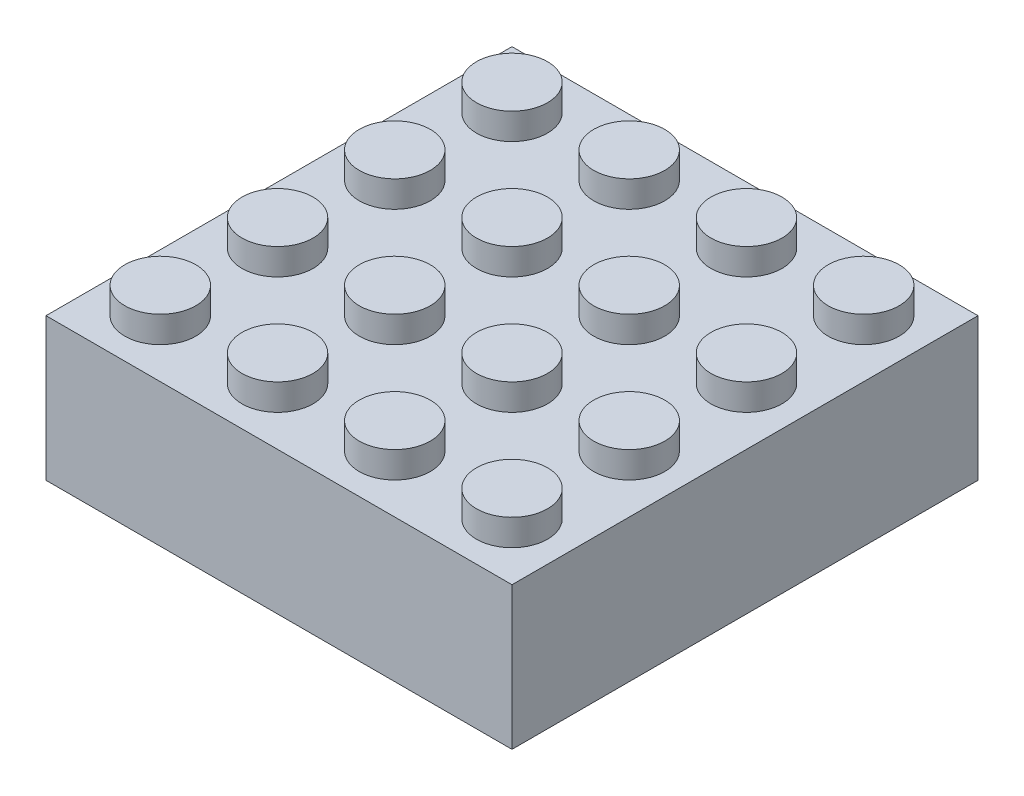
from build123d import *

# Parameters (mm, degrees)
SKETCH2_R              = 2.425
BOSS_EXTRUDE1_DEPTH    = 1.8
BOSS_EXTRUDE1_2_DEPTH  = 1.8
BOSS_EXTRUDE1_3_DEPTH  = 1.8
BOSS_EXTRUDE1_4_DEPTH  = 1.8
BOSS_EXTRUDE1_5_DEPTH  = 1.8
BOSS_EXTRUDE1_6_DEPTH  = 1.8
BOSS_EXTRUDE1_7_DEPTH  = 1.8
BOSS_EXTRUDE1_8_DEPTH  = 1.8
BOSS_EXTRUDE1_9_DEPTH  = 1.8
BOSS_EXTRUDE1_10_DEPTH = 1.8
BOSS_EXTRUDE1_11_DEPTH = 1.8
BOSS_EXTRUDE1_12_DEPTH = 1.8
BOSS_EXTRUDE1_13_DEPTH = 1.8
BOSS_EXTRUDE1_14_DEPTH = 1.8
BOSS_EXTRUDE1_15_DEPTH = 1.8
BOSS_EXTRUDE1_16_DEPTH = 1.8
SKETCH1_W              = 31.8
SKETCH1_H              = 31.8
BOSS_EXTRUDE2_DEPTH    = 9.73
CUT_EXTRUDE1_DEPTH     = 6.63
SKETCH9_W              = 8.211044263
SKETCH9_H              = 1.75
BOSS_EXTRUDE4_DEPTH    = 1.5
BOSS_EXTRUDE5_DEPTH    = 8.211044
CUT_EXTRUDE4_DEPTH     = 8.211044
CIRPATTERN3_COUNT      = 6
BOSS_EXTRUDE6_DEPTH    = 0.3
CIRPATTERN4_COUNT      = 6
BOSS_EXTRUDE7_DEPTH    = 2
CIRPATTERN5_COUNT      = 6
MIRROR2_COPY_1_DEPTH   = 2
MIRROR2_COPY_2_DEPTH   = 2
MIRROR2_COPY_3_DEPTH   = 2
MIRROR2_COPY_4_DEPTH   = 2
MIRROR2_COPY_5_DEPTH   = 2
MIRROR2_COPY_6_DEPTH   = 2


with BuildPart() as part:
    # Sketch2 → Boss-Extrude1 (new body)
    with BuildSketch(Plane(origin=(0, 0, 0), x_dir=(1, 0, 0), z_dir=(0, 1, 0))):
        with Locations((3.9, 27.9)):
            Circle(SKETCH2_R)
    extrude(amount=BOSS_EXTRUDE1_DEPTH)

    # Sketch1 → Boss-Extrude2 (add)
    with BuildSketch(Plane(origin=(0, 0, 0), x_dir=(1, 0, 0), z_dir=(0, 1, 0))):
        with Locations((15.9, 15.9)):
            Rectangle(SKETCH1_W, SKETCH1_H)
    extrude(amount=-BOSS_EXTRUDE2_DEPTH)

    # Sketch4 → Cut-Extrude1 (cut)
    with BuildSketch(Plane.XZ.offset(9.73)):
        Polygon((26.085733965, -15.874437919), (21.016403127, -7.092489065), (10.805424678, -7.07984512), (5.714275589, -15.929121347), (10.830590574, -24.734643054), (21.015442313, -24.708069014), align=None)
    extrude(amount=-CUT_EXTRUDE1_DEPTH, mode=Mode.SUBTRACT)

    # Sketch9 → Boss-Extrude4 (add)
    with BuildSketch(Plane.XZ.offset(9.73)):
        with Locations((15.910946043, -6.206083389)):
            Rectangle(SKETCH9_W, SKETCH9_H)
    boss_extrude4 = extrude(amount=BOSS_EXTRUDE4_DEPTH)

    # Sketch10 → Boss-Extrude5 (add)
    with BuildSketch(Plane(origin=(20.016468174, 0, 0), x_dir=(0, 0, -1), z_dir=(1, 0, 0))):
        Polygon((7.081083389, -11.23), (7.981083389, -9.83), (7.081083389, -9.73), align=None)
    boss_extrude5 = extrude(amount=-BOSS_EXTRUDE5_DEPTH)

    # Sketch11 → Cut-Extrude4 (cut)
    with BuildSketch(Plane(origin=(20.016468174, 0, 0), x_dir=(0, 0, -1), z_dir=(1, 0, 0))):
        Polygon((6.331083389, -11.23), (5.331083389, -9.73), (5.331083389, -11.23), align=None)
    cut_extrude4 = extrude(amount=-CUT_EXTRUDE4_DEPTH, mode=Mode.SUBTRACT)

    # CirPattern3: Boss-Extrude4, Boss-Extrude5, Cut-Extrude4 ×6 about axis
    cirpattern3_axis = Axis((15.9, 0, -15.9), (0, 1, 0))
    for i in range(1, CIRPATTERN3_COUNT):
        add(boss_extrude4.rotate(cirpattern3_axis, i * 360 / CIRPATTERN3_COUNT))
        add(boss_extrude5.rotate(cirpattern3_axis, i * 360 / CIRPATTERN3_COUNT))
        add(cut_extrude4.rotate(cirpattern3_axis, i * 360 / CIRPATTERN3_COUNT), mode=Mode.SUBTRACT)

    # Sketch14 → Boss-Extrude6 (add, symmetric)
    with BuildSketch(Plane(origin=(10.895248778, 0, -18.812913342), x_dir=(0.86535523, 0, 0.501158983), z_dir=(-0.501158983, 0, 0.86535523))):
        Polygon((14.624999456, -3.1), (14.624999456, -8.639676715), (14.024999456, -3.1), align=None)
    boss_extrude6 = extrude(amount=BOSS_EXTRUDE6_DEPTH, both=True)

    # CirPattern4: Boss-Extrude6 ×6 about axis
    cirpattern4_axis = Axis((15.9, 0, -15.9), (0, 1, 0))
    for i in range(1, CIRPATTERN4_COUNT):
        add(boss_extrude6.rotate(cirpattern4_axis, i * 360 / CIRPATTERN4_COUNT))

    # Sketch18 → Boss-Extrude7 (add)
    with BuildSketch(Plane.ZY.offset(-11.805423911)):
        Polygon((-7.081083389, -11.23), (-7.081083389, -9.73), (-5.331083389, -9.73), (-6.331083389, -11.23), align=None)
    boss_extrude7 = extrude(amount=BOSS_EXTRUDE7_DEPTH)

    # CirPattern5: Boss-Extrude7 ×6 about axis
    cirpattern5_axis = Axis((15.9, 0, -15.9), (0, 1, 0))
    for i in range(1, CIRPATTERN5_COUNT):
        add(boss_extrude7.rotate(cirpattern5_axis, i * 360 / CIRPATTERN5_COUNT))

    # Mirror1: Boss-Extrude7 across plane
    add(boss_extrude7.mirror(Plane(origin=(15.919664079, 0, -0.019712838), x_dir=(0.001238269, 0, 0.999999233), z_dir=(0.999999233, 0, -0.001238269))))

    # Mirror2 copy 1 sketch → Mirror2 copy 1 (add)
    with BuildSketch(Plane(origin=(4.205990344, 0, -4.374997115), x_dir=(-0.86478448, 0, 0.50214321), z_dir=(0.50214321, 0, 0.86478448))):
        Polygon((-7.081083389, 11.23), (-7.081083389, 9.73), (-5.331083389, 9.73), (-6.331083389, 11.23), align=None)
    extrude(amount=MIRROR2_COPY_1_DEPTH)

    # Mirror2 copy 2 sketch → Mirror2 copy 2 (add)
    with BuildSketch(Plane(origin=(0.072049895, 0, -20.264807991), x_dir=(-0.867261016, 0, -0.497853724), z_dir=(-0.497853724, 0, 0.867261016))):
        Polygon((-7.081083389, 11.23), (-7.081083389, 9.73), (-5.331083389, 9.73), (-6.331083389, 11.23), align=None)
    extrude(amount=MIRROR2_COPY_2_DEPTH)

    # Mirror2 copy 3 sketch → Mirror2 copy 3 (add)
    with BuildSketch(Plane(origin=(11.766059551, 0, -31.789810877), x_dir=(-0.002476536, 0, -0.999996933), z_dir=(-0.999996933, 0, 0.002476536))):
        Polygon((-7.081083389, 11.23), (-7.081083389, 9.73), (-5.331083389, 9.73), (-6.331083389, 11.23), align=None)
    extrude(amount=MIRROR2_COPY_3_DEPTH)

    # Mirror2 copy 4 sketch → Mirror2 copy 4 (add)
    with BuildSketch(Plane(origin=(27.594009656, 0, -27.425002885), x_dir=(0.86478448, 0, -0.50214321), z_dir=(-0.50214321, 0, -0.86478448))):
        Polygon((-7.081083389, 11.23), (-7.081083389, 9.73), (-5.331083389, 9.73), (-6.331083389, 11.23), align=None)
    extrude(amount=MIRROR2_COPY_4_DEPTH)

    # Mirror2 copy 5 sketch → Mirror2 copy 5 (add)
    with BuildSketch(Plane(origin=(31.727950105, 0, -11.535192009), x_dir=(0.867261016, 0, 0.497853724), z_dir=(0.497853724, 0, -0.867261016))):
        Polygon((-7.081083389, 11.23), (-7.081083389, 9.73), (-5.331083389, 9.73), (-6.331083389, 11.23), align=None)
    extrude(amount=MIRROR2_COPY_5_DEPTH)

    # Mirror2 copy 6 sketch → Mirror2 copy 6 (add)
    with BuildSketch(Plane(origin=(20.033940449, 0, -0.010189123), x_dir=(0.002476536, 0, 0.999996933), z_dir=(0.999996933, 0, -0.002476536))):
        Polygon((-7.081083389, 11.23), (-7.081083389, 9.73), (-5.331083389, 9.73), (-6.331083389, 11.23), align=None)
    extrude(amount=MIRROR2_COPY_6_DEPTH)


with BuildPart() as body_2:
    # Sketch2 → Boss-Extrude1 2 (new body)
    with BuildSketch(Plane(origin=(0, 0, 0), x_dir=(1, 0, 0), z_dir=(0, 1, 0))):
        with Locations((11.9, 27.9)):
            Circle(SKETCH2_R)
    extrude(amount=BOSS_EXTRUDE1_2_DEPTH)


with BuildPart() as body_3:
    # Sketch2 → Boss-Extrude1 3 (new body)
    with BuildSketch(Plane(origin=(0, 0, 0), x_dir=(1, 0, 0), z_dir=(0, 1, 0))):
        with Locations((19.9, 27.9)):
            Circle(SKETCH2_R)
    extrude(amount=BOSS_EXTRUDE1_3_DEPTH)


with BuildPart() as body_4:
    # Sketch2 → Boss-Extrude1 4 (new body)
    with BuildSketch(Plane(origin=(0, 0, 0), x_dir=(1, 0, 0), z_dir=(0, 1, 0))):
        with Locations((27.9, 27.9)):
            Circle(SKETCH2_R)
    extrude(amount=BOSS_EXTRUDE1_4_DEPTH)


with BuildPart() as body_5:
    # Sketch2 → Boss-Extrude1 5 (new body)
    with BuildSketch(Plane(origin=(0, 0, 0), x_dir=(1, 0, 0), z_dir=(0, 1, 0))):
        with Locations((11.9, 19.9)):
            Circle(SKETCH2_R)
    extrude(amount=BOSS_EXTRUDE1_5_DEPTH)


with BuildPart() as body_6:
    # Sketch2 → Boss-Extrude1 6 (new body)
    with BuildSketch(Plane(origin=(0, 0, 0), x_dir=(1, 0, 0), z_dir=(0, 1, 0))):
        with Locations((19.9, 19.9)):
            Circle(SKETCH2_R)
    extrude(amount=BOSS_EXTRUDE1_6_DEPTH)


with BuildPart() as body_7:
    # Sketch2 → Boss-Extrude1 7 (new body)
    with BuildSketch(Plane(origin=(0, 0, 0), x_dir=(1, 0, 0), z_dir=(0, 1, 0))):
        with Locations((27.9, 19.9)):
            Circle(SKETCH2_R)
    extrude(amount=BOSS_EXTRUDE1_7_DEPTH)


with BuildPart() as body_8:
    # Sketch2 → Boss-Extrude1 8 (new body)
    with BuildSketch(Plane(origin=(0, 0, 0), x_dir=(1, 0, 0), z_dir=(0, 1, 0))):
        with Locations((11.9, 11.9)):
            Circle(SKETCH2_R)
    extrude(amount=BOSS_EXTRUDE1_8_DEPTH)


with BuildPart() as body_9:
    # Sketch2 → Boss-Extrude1 9 (new body)
    with BuildSketch(Plane(origin=(0, 0, 0), x_dir=(1, 0, 0), z_dir=(0, 1, 0))):
        with Locations((19.9, 11.9)):
            Circle(SKETCH2_R)
    extrude(amount=BOSS_EXTRUDE1_9_DEPTH)


with BuildPart() as body_10:
    # Sketch2 → Boss-Extrude1 10 (new body)
    with BuildSketch(Plane(origin=(0, 0, 0), x_dir=(1, 0, 0), z_dir=(0, 1, 0))):
        with Locations((27.9, 11.9)):
            Circle(SKETCH2_R)
    extrude(amount=BOSS_EXTRUDE1_10_DEPTH)


with BuildPart() as body_11:
    # Sketch2 → Boss-Extrude1 11 (new body)
    with BuildSketch(Plane(origin=(0, 0, 0), x_dir=(1, 0, 0), z_dir=(0, 1, 0))):
        with Locations((11.9, 3.9)):
            Circle(SKETCH2_R)
    extrude(amount=BOSS_EXTRUDE1_11_DEPTH)


with BuildPart() as body_12:
    # Sketch2 → Boss-Extrude1 12 (new body)
    with BuildSketch(Plane(origin=(0, 0, 0), x_dir=(1, 0, 0), z_dir=(0, 1, 0))):
        with Locations((19.9, 3.9)):
            Circle(SKETCH2_R)
    extrude(amount=BOSS_EXTRUDE1_12_DEPTH)


with BuildPart() as body_13:
    # Sketch2 → Boss-Extrude1 13 (new body)
    with BuildSketch(Plane(origin=(0, 0, 0), x_dir=(1, 0, 0), z_dir=(0, 1, 0))):
        with Locations((27.9, 3.9)):
            Circle(SKETCH2_R)
    extrude(amount=BOSS_EXTRUDE1_13_DEPTH)


with BuildPart() as body_14:
    # Sketch2 → Boss-Extrude1 14 (new body)
    with BuildSketch(Plane(origin=(0, 0, 0), x_dir=(1, 0, 0), z_dir=(0, 1, 0))):
        with Locations((3.9, 19.9)):
            Circle(SKETCH2_R)
    extrude(amount=BOSS_EXTRUDE1_14_DEPTH)


with BuildPart() as body_15:
    # Sketch2 → Boss-Extrude1 15 (new body)
    with BuildSketch(Plane(origin=(0, 0, 0), x_dir=(1, 0, 0), z_dir=(0, 1, 0))):
        with Locations((3.9, 11.9)):
            Circle(SKETCH2_R)
    extrude(amount=BOSS_EXTRUDE1_15_DEPTH)


with BuildPart() as body_16:
    # Sketch2 → Boss-Extrude1 16 (new body)
    with BuildSketch(Plane(origin=(0, 0, 0), x_dir=(1, 0, 0), z_dir=(0, 1, 0))):
        with Locations((3.9, 3.9)):
            Circle(SKETCH2_R)
    extrude(amount=BOSS_EXTRUDE1_16_DEPTH)


solid = Compound([part.part, body_2.part, body_3.part, body_4.part, body_5.part, body_6.part, body_7.part, body_8.part, body_9.part, body_10.part, body_11.part, body_12.part, body_13.part, body_14.part, body_15.part, body_16.part])
